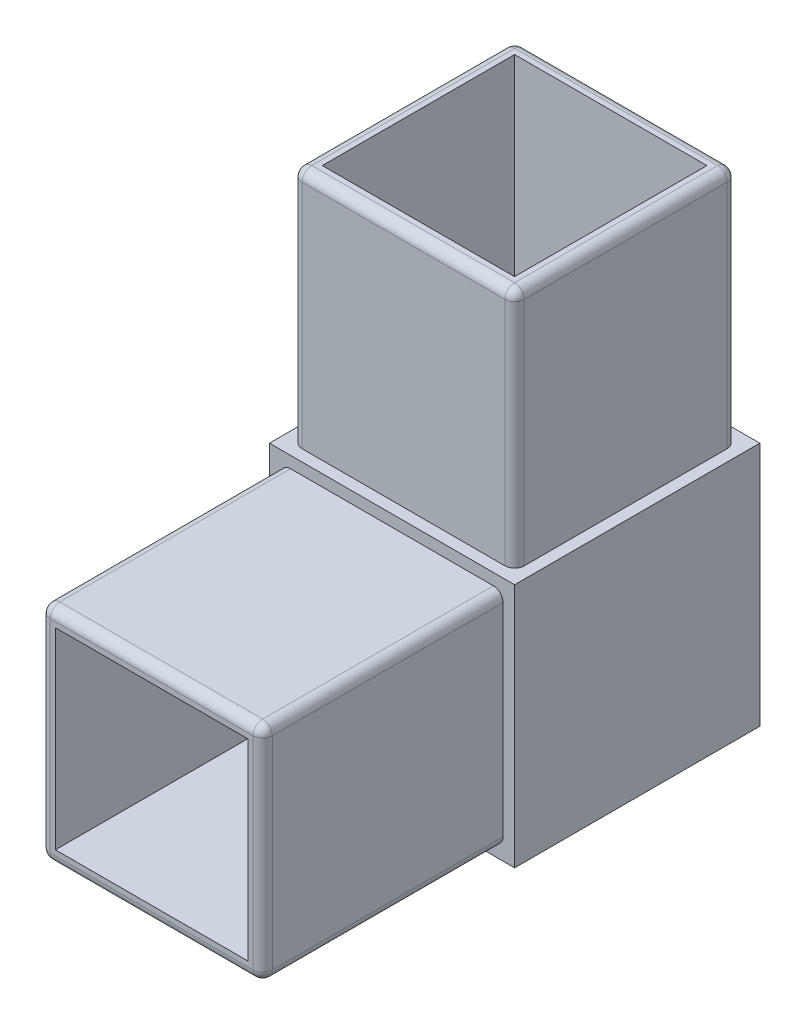
from build123d import *

# Parameters (mm, degrees)
SKETCH1_W           = 25.5
SKETCH1_H           = 25.5
BOSS_EXTRUDE1_DEPTH = 25.5
SKETCH3_W           = 23.1
SKETCH3_H           = 23.1
BOSS_EXTRUDE2_DEPTH = 25
SKETCH5_W           = 23.1
SKETCH5_H           = 23.1
BOSS_EXTRUDE3_DEPTH = 25
SKETCH6_W           = 20
SKETCH6_H           = 20
CUT_EXTRUDE1_DEPTH  = 45.5
SKETCH7_W           = 20
SKETCH7_H           = 20
CUT_EXTRUDE2_DEPTH  = 45.5
FILLET1_R           = 1


with BuildPart() as part:
    # Sketch1 → Boss-Extrude1 (new body)
    with BuildSketch(Plane(origin=(0, 0, 0), x_dir=(1, 0, 0), z_dir=(0, 1, 0))):
        Rectangle(SKETCH1_W, SKETCH1_H)
    extrude(amount=BOSS_EXTRUDE1_DEPTH)

    # Sketch3 → Boss-Extrude2 (add)
    with BuildSketch(Plane(origin=(0, 25.5, 0), x_dir=(1, 0, 0), z_dir=(0, 1, 0))):
        Rectangle(SKETCH3_W, SKETCH3_H)
    extrude(amount=BOSS_EXTRUDE2_DEPTH)

    # Sketch5 → Boss-Extrude3 (add)
    with BuildSketch(Plane.XY.offset(12.75)):
        with Locations((0, 12.75)):
            Rectangle(SKETCH5_W, SKETCH5_H)
    extrude(amount=BOSS_EXTRUDE3_DEPTH)

    # Sketch6 → Cut-Extrude1 (cut)
    with BuildSketch(Plane.XY.offset(37.75)):
        with Locations((0, 12.75)):
            Rectangle(SKETCH6_W, SKETCH6_H)
    extrude(amount=-CUT_EXTRUDE1_DEPTH, mode=Mode.SUBTRACT)

    # Sketch7 → Cut-Extrude2 (cut)
    with BuildSketch(Plane(origin=(0, 50.5, 0), x_dir=(1, 0, 0), z_dir=(0, 1, 0))):
        Rectangle(SKETCH7_W, SKETCH7_H)
    extrude(amount=-CUT_EXTRUDE2_DEPTH, mode=Mode.SUBTRACT)

    # Fillet1
    fillet1_edges = [part.edges().sort_by_distance(p)[0] for p in [
        (11.55, 38, 11.55),
        (11.55, 38, -11.55),
        (-11.55, 38, -11.55),
        (-11.55, 38, 11.55),
        (11.55, 50.5, 0),
        (0, 50.5, -11.55),
        (-11.55, 50.5, 0),
        (0, 50.5, 11.55),
        (11.55, 1.2, 25.25),
        (11.55, 24.3, 25.25),
        (-11.55, 24.3, 25.25),
        (-11.55, 1.2, 25.25),
        (11.55, 12.75, 37.75),
        (0, 24.3, 37.75),
        (-11.55, 12.75, 37.75),
        (0, 1.2, 37.75),
    ]]
    fillet(fillet1_edges, radius=FILLET1_R)


solid = part.part
